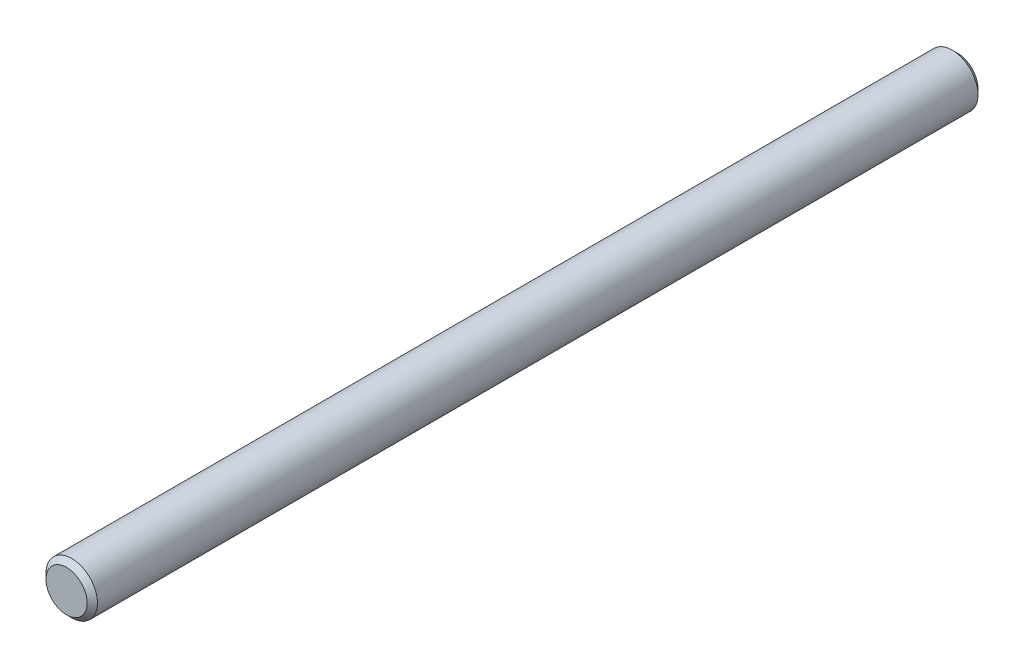
from build123d import *

# Parameters (mm, degrees)
SKETCH1_R      = 6.35
EXTRUDE1_DEPTH = 110
CHAMFER1_SIZE  = 1.27


with BuildPart() as part:
    # Sketch1 → Extrude1 (new body, symmetric)
    with BuildSketch(Plane.XY):
        Circle(SKETCH1_R)
    extrude(amount=EXTRUDE1_DEPTH, both=True)

    # Chamfer1
    chamfer1_edges = [part.edges().sort_by_distance(p)[0] for p in [
        (-6.35, 0, -110),
        (-6.35, 0, 110),
    ]]
    chamfer(chamfer1_edges, length=CHAMFER1_SIZE)


solid = part.part
